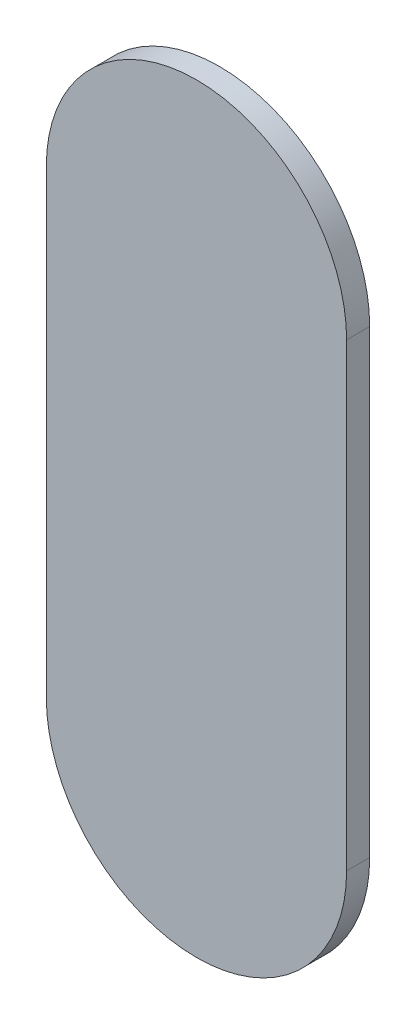
from build123d import *

# Parameters (mm, degrees)
BOSS_EXTRUDE1_DEPTH = 0.5


with BuildPart() as part:
    # Sketch1 → Boss-Extrude1 (new body)
    with BuildSketch(Plane.XY):
        with BuildLine():
            Line((-37.262343372, 11.062531061), (-37.262343372, 21.033464005))
            ThreePointArc((-37.262343372, 21.033464005), (-34.006470963, 24.289336414), (-30.750598554, 21.033464005))
            Line((-30.750598554, 21.033464005), (-30.750598554, 11.062531061))
            ThreePointArc((-30.750598554, 11.062531061), (-34.006470963, 7.806658653), (-37.262343372, 11.062531061))
        make_face()
    extrude(amount=BOSS_EXTRUDE1_DEPTH)


solid = part.part
